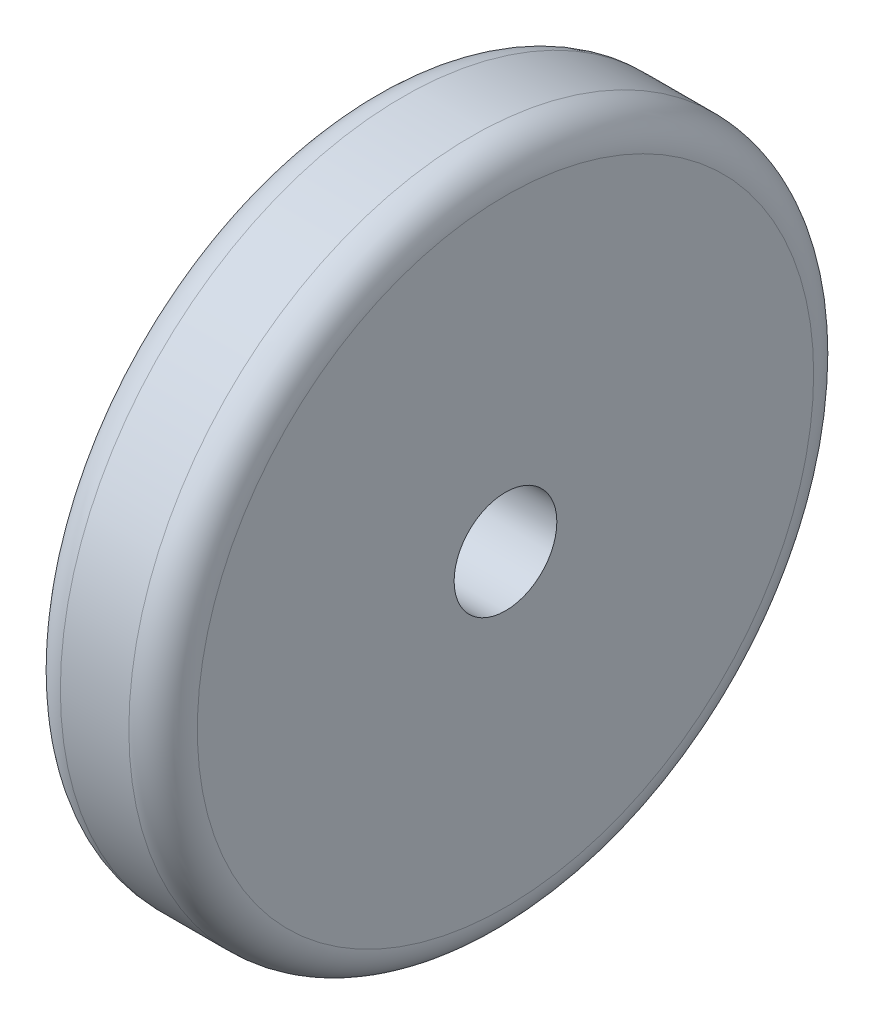
from build123d import *

# Parameters (mm, degrees)
SKETCH_1_R          = 50
EXTRUDE_1_DEPTH     = 20
FILLET_1_R          = 5
SKETCH_2_R          = 7.5
CUT_EXTRUDE_1_DEPTH = 30


with BuildPart() as part:
    # 草图1 → 凸台-拉伸1 (new body)
    with BuildSketch(Plane(origin=(0, 0, 0), x_dir=(0, 0, -1), z_dir=(1, 0, 0))):
        Circle(SKETCH_1_R)
    extrude(amount=EXTRUDE_1_DEPTH)

    # 圆角1
    fillet_1_edges = [part.edges().sort_by_distance(p)[0] for p in [
        (0, 0, 50),
        (20, 0, 50),
    ]]
    fillet(fillet_1_edges, radius=FILLET_1_R)

    # 草图2 → 切除-拉伸1 (cut)
    with BuildSketch(Plane.ZY):
        Circle(SKETCH_2_R)
    extrude(amount=-CUT_EXTRUDE_1_DEPTH, mode=Mode.SUBTRACT)


solid = part.part
